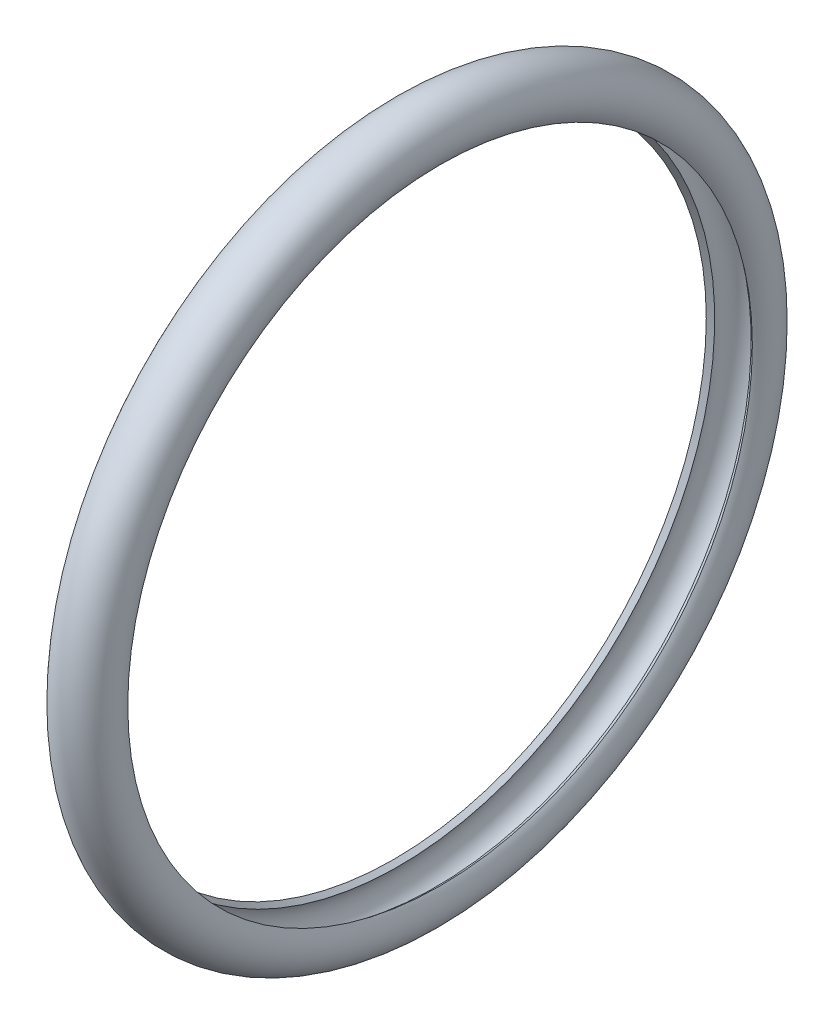
from build123d import *


with BuildPart() as part:
    # Sketch1 → Revolve1 (revolve)
    with BuildSketch(Plane.XY):
        with BuildLine():
            Line((1.129726799, 12.97), (1.330039924, 13.11958159))
            ThreePointArc((1.330039924, 13.11958159), (2.087223536, 14.63), (2.844407147, 13.11958159))
            Line((2.844407147, 13.11958159), (3.044720272, 12.97))
            ThreePointArc((3.044720272, 12.97), (2.087223536, 14.88), (1.129726799, 12.97))
        make_face()
    revolve(axis=Axis((-88.99, 0, 0), (1, 0, 0)))


solid = part.part
